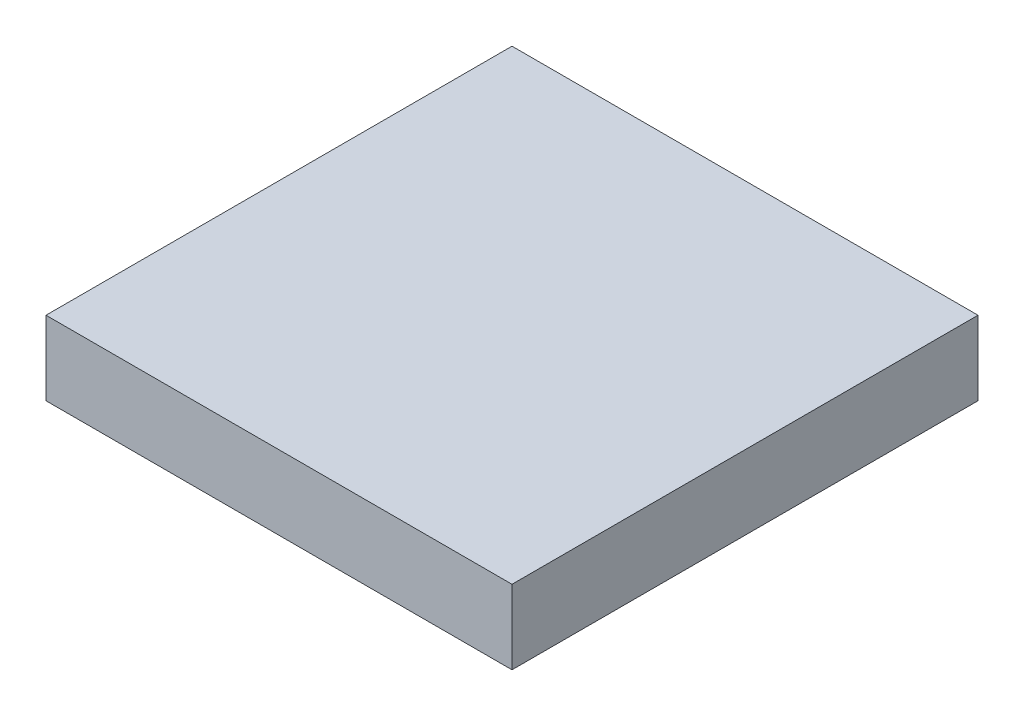
from build123d import *

# Parameters (mm, degrees)
SKETCH3_W           = 10
SKETCH3_H           = 10
BOSS_EXTRUDE1_DEPTH = 1.59


with BuildPart() as part:
    # Sketch3 → Boss-Extrude1 (new body)
    with BuildSketch(Plane(origin=(0, 0, 0), x_dir=(1, 0, 0), z_dir=(0, 1, 0))):
        with Locations((5, 5)):
            Rectangle(SKETCH3_W, SKETCH3_H)
    extrude(amount=BOSS_EXTRUDE1_DEPTH)


solid = part.part
